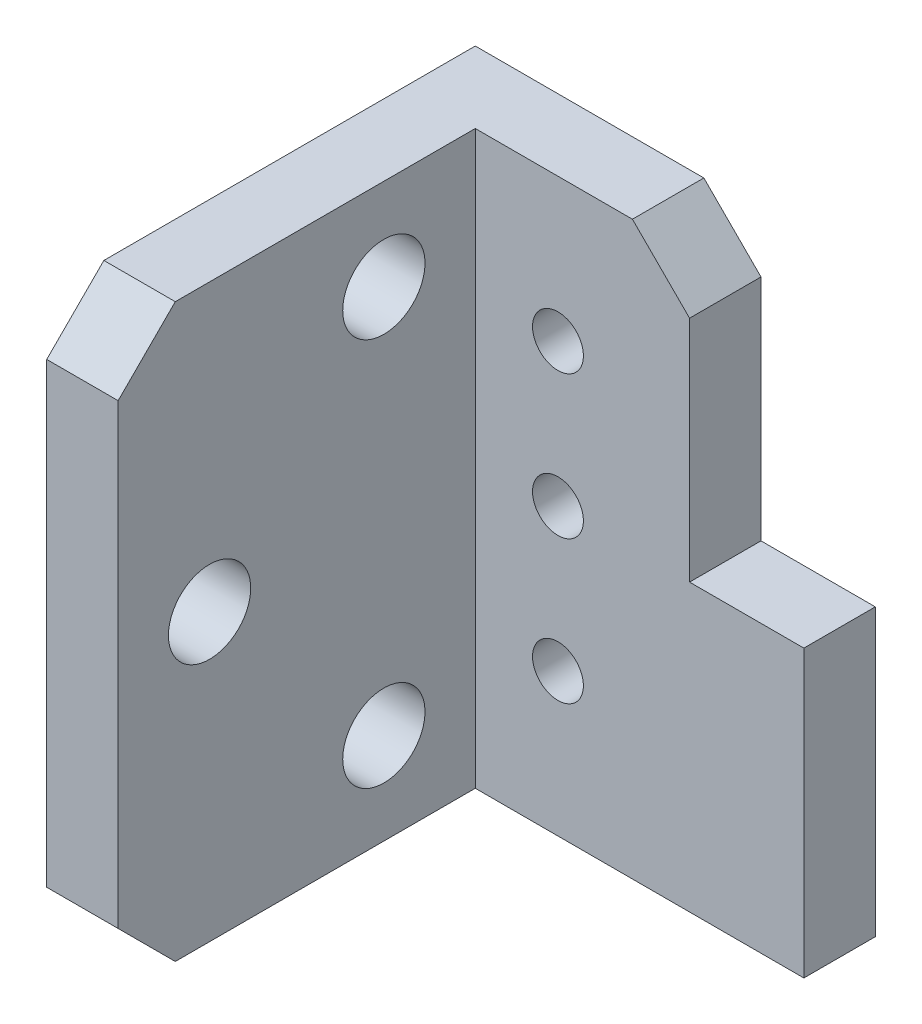
from build123d import *

# Parameters (mm, degrees)
BOSS_EXTRUDE1_DEPTH   = 25.4
F_6_CLEARANCE_HOLE1_D = 3.6576
CHAMFER1_SIZE         = 2.54
F_4_40_TAPPED_HOLE1_D = 2.2606
SKETCH8_W             = 7.62
SKETCH8_H             = 12.7
BOSS_EXTRUDE2_DEPTH   = 3.175


with BuildPart() as part:
    # Sketch1 → Boss-Extrude1 (new body)
    with BuildSketch(Plane(origin=(0, 0, 0), x_dir=(1, 0, 0), z_dir=(0, 1, 0))):
        Polygon((0, 0), (12.7, 0), (12.7, -3.175), (3.175, -3.175), (3.175, -19.05), (0, -19.05), align=None)
    extrude(amount=BOSS_EXTRUDE1_DEPTH)

    # 6 Clearance Hole1 (through all)
    with Locations(Plane.ZY):
        with Locations((7.239, 4.064), (7.239, 21.336), (14.986, 12.7)):
            Hole(F_6_CLEARANCE_HOLE1_D / 2)

    # Chamfer1
    chamfer1_edges = [part.edges().sort_by_distance(p)[0] for p in [
        (12.7, 25.4, 1.5875),
        (12.7, 0, 1.5875),
        (1.5875, 25.4, 19.05),
        (1.5875, 0, 19.05),
    ]]
    chamfer(chamfer1_edges, length=CHAMFER1_SIZE)

    # 4-40 Tapped Hole1 (through all)
    with Locations(Plane(origin=(0, 0, 0), x_dir=(-1, 0, 0), z_dir=(0, 0, -1))):
        with Locations((-6.8499944, 6.35), (-6.8499944, 12.7), (-6.8499944, 19.05)):
            Hole(F_4_40_TAPPED_HOLE1_D / 2)

    # Sketch8 → Boss-Extrude2 (add)
    with BuildSketch(Plane(origin=(0, 0, 0), x_dir=(-1, 0, 0), z_dir=(0, 0, -1))):
        with Locations((-13.97, 6.35)):
            Rectangle(SKETCH8_W, SKETCH8_H)
    extrude(amount=-BOSS_EXTRUDE2_DEPTH)


solid = part.part
